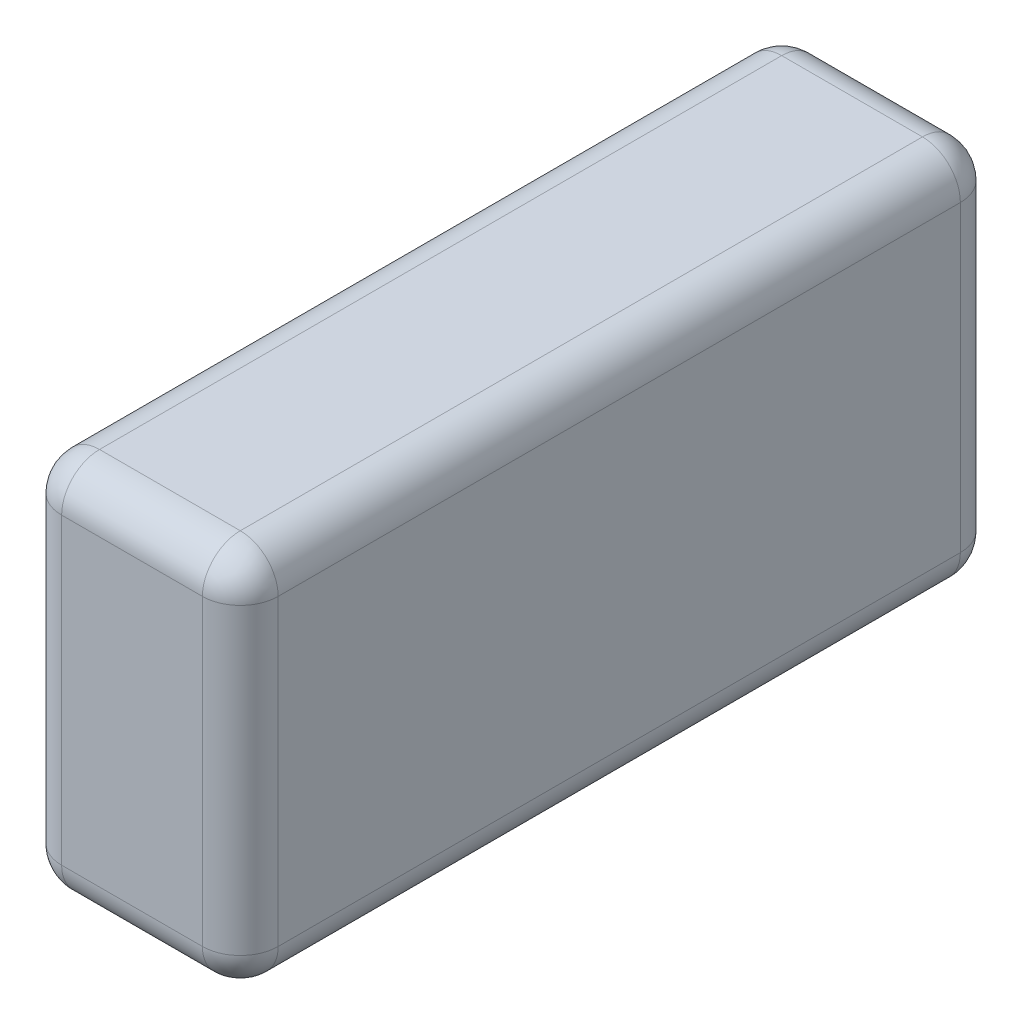
from build123d import *

# Parameters (mm, degrees)
SKETCH1_W           = 700
SKETCH1_H           = 350
BOSS_EXTRUDE1_DEPTH = 200
FILLET1_R           = 35


with BuildPart() as part:
    # Sketch1 → Boss-Extrude1 (new body)
    with BuildSketch(Plane(origin=(0, 0, 0), x_dir=(0, 0, -1), z_dir=(1, 0, 0))):
        with Locations((0, 30.497925311)):
            Rectangle(SKETCH1_W, SKETCH1_H)
    extrude(amount=BOSS_EXTRUDE1_DEPTH)

    # Fillet1
    fillet1_edges = [part.edges().sort_by_distance(p)[0] for p in [
        (200, 30.497925311, 350),
        (200, -144.502074689, 0),
        (200, 30.497925311, -350),
        (0, -144.502074689, 0),
        (0, 30.497925311, 350),
        (0, 205.497925311, 0),
        (0, 30.497925311, -350),
        (100, -144.502074689, -350),
        (100, -144.502074689, 350),
        (100, 205.497925311, 350),
        (100, 205.497925311, -350),
        (200, 205.497925311, 0),
    ]]
    fillet(fillet1_edges, radius=FILLET1_R)


solid = part.part
